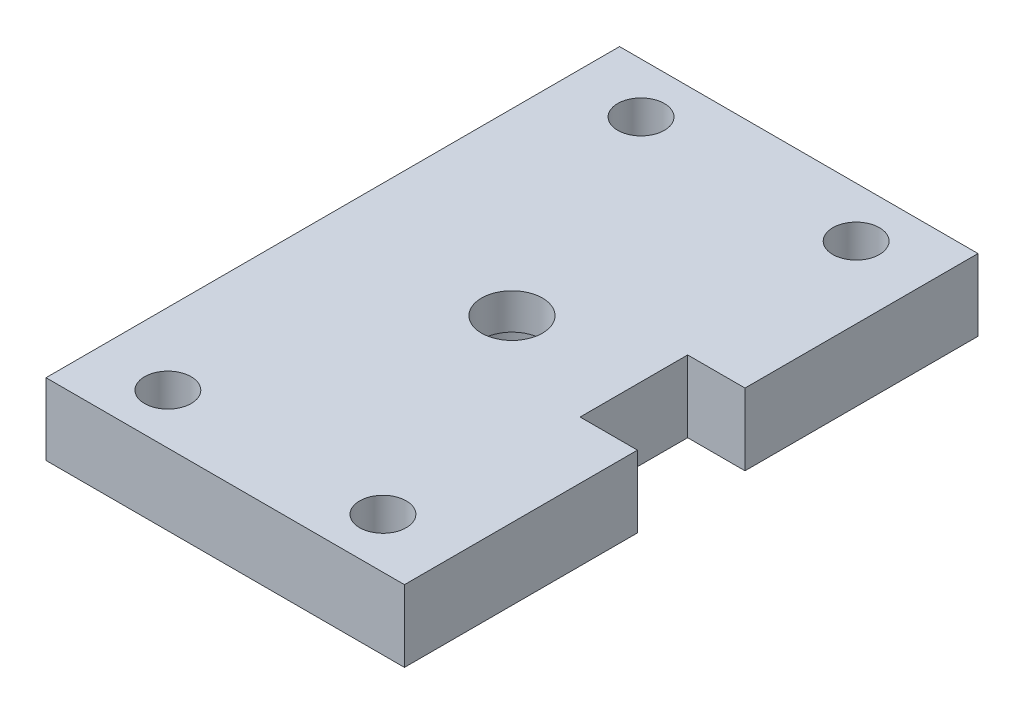
from build123d import *

# Parameters (mm, degrees)
SKETCH1_W           = 50
SKETCH1_H           = 80
BOSS_EXTRUDE1_DEPTH = 10
CUT_EXTRUDE1_REACH  = 12
SKETCH2_R           = 4.25
CUT_EXTRUDE3_REACH  = 12
SKETCH5_R           = 3.25
SKETCH7_R           = 7.5
CUT_EXTRUDE4_DEPTH  = 5
SKETCH10_W          = 8
SKETCH10_H          = 15
CUT_EXTRUDE5_DEPTH  = 11


with BuildPart() as part:
    # Sketch1 → Boss-Extrude1 (new body)
    with BuildSketch(Plane(origin=(0, 0, 0), x_dir=(1, 0, 0), z_dir=(0, 1, 0))):
        with Locations((5.890258642, -6.741379093)):
            Rectangle(SKETCH1_W, SKETCH1_H)
    extrude(amount=BOSS_EXTRUDE1_DEPTH)

    # Sketch2 → Cut-Extrude1 (cut, up to next)
    with BuildSketch(Plane.XZ, mode=Mode.PRIVATE) as cut_extrude1_sk1:
        with Locations((5.890258642, 6.741379093)):
            Circle(SKETCH2_R)
    cut_extrude1_tool1 = extrude(cut_extrude1_sk1.sketch, amount=-CUT_EXTRUDE1_REACH, mode=Mode.PRIVATE) & part.part
    add(cut_extrude1_tool1.solids().sort_by_distance((5.890259, 0, 6.741379))[0], mode=Mode.SUBTRACT)

    # Sketch5 → Cut-Extrude3 (cut, up to next)
    with BuildSketch(Plane(origin=(0, 10, 0), x_dir=(1, 0, 0), z_dir=(0, 1, 0)), mode=Mode.PRIVATE) as cut_extrude3_sk1:
        with Locations((-9.109741358, -39.741379093)):
            Circle(SKETCH5_R)
    cut_extrude3_tool1 = extrude(cut_extrude3_sk1.sketch, amount=-CUT_EXTRUDE3_REACH, mode=Mode.PRIVATE) & part.part
    add(cut_extrude3_tool1.solids().sort_by_distance((-9.109741, 10, 39.741379))[0], mode=Mode.SUBTRACT)
    # Sketch5 → Cut-Extrude3 (cut, up to next)
    with BuildSketch(Plane(origin=(0, 10, 0), x_dir=(1, 0, 0), z_dir=(0, 1, 0)), mode=Mode.PRIVATE) as cut_extrude3_sk2:
        with Locations((20.890258642, -39.741379093)):
            Circle(SKETCH5_R)
    cut_extrude3_tool2 = extrude(cut_extrude3_sk2.sketch, amount=-CUT_EXTRUDE3_REACH, mode=Mode.PRIVATE) & part.part
    add(cut_extrude3_tool2.solids().sort_by_distance((20.890259, 10, 39.741379))[0], mode=Mode.SUBTRACT)
    # Sketch5 → Cut-Extrude3 (cut, up to next)
    with BuildSketch(Plane(origin=(0, 10, 0), x_dir=(1, 0, 0), z_dir=(0, 1, 0)), mode=Mode.PRIVATE) as cut_extrude3_sk3:
        with Locations((-9.109741358, 26.258620907)):
            Circle(SKETCH5_R)
    cut_extrude3_tool3 = extrude(cut_extrude3_sk3.sketch, amount=-CUT_EXTRUDE3_REACH, mode=Mode.PRIVATE) & part.part
    add(cut_extrude3_tool3.solids().sort_by_distance((-9.109741, 10, -26.258621))[0], mode=Mode.SUBTRACT)
    # Sketch5 → Cut-Extrude3 (cut, up to next)
    with BuildSketch(Plane(origin=(0, 10, 0), x_dir=(1, 0, 0), z_dir=(0, 1, 0)), mode=Mode.PRIVATE) as cut_extrude3_sk4:
        with Locations((20.890258642, 26.258620907)):
            Circle(SKETCH5_R)
    cut_extrude3_tool4 = extrude(cut_extrude3_sk4.sketch, amount=-CUT_EXTRUDE3_REACH, mode=Mode.PRIVATE) & part.part
    add(cut_extrude3_tool4.solids().sort_by_distance((20.890259, 10, -26.258621))[0], mode=Mode.SUBTRACT)

    # Sketch7 → Cut-Extrude4 (cut)
    with BuildSketch(Plane.XZ):
        with Locations((5.890258642, 6.741379093)):
            Circle(SKETCH7_R)
    extrude(amount=-CUT_EXTRUDE4_DEPTH, mode=Mode.SUBTRACT)

    # Sketch10 → Cut-Extrude5 (cut, through all)
    with BuildSketch(Plane(origin=(0, 10, 0), x_dir=(1, 0, 0), z_dir=(0, 1, 0))):
        with Locations((26.890258642, -6.741379093)):
            Rectangle(SKETCH10_W, SKETCH10_H)
    extrude(amount=-CUT_EXTRUDE5_DEPTH, mode=Mode.SUBTRACT)


solid = part.part
